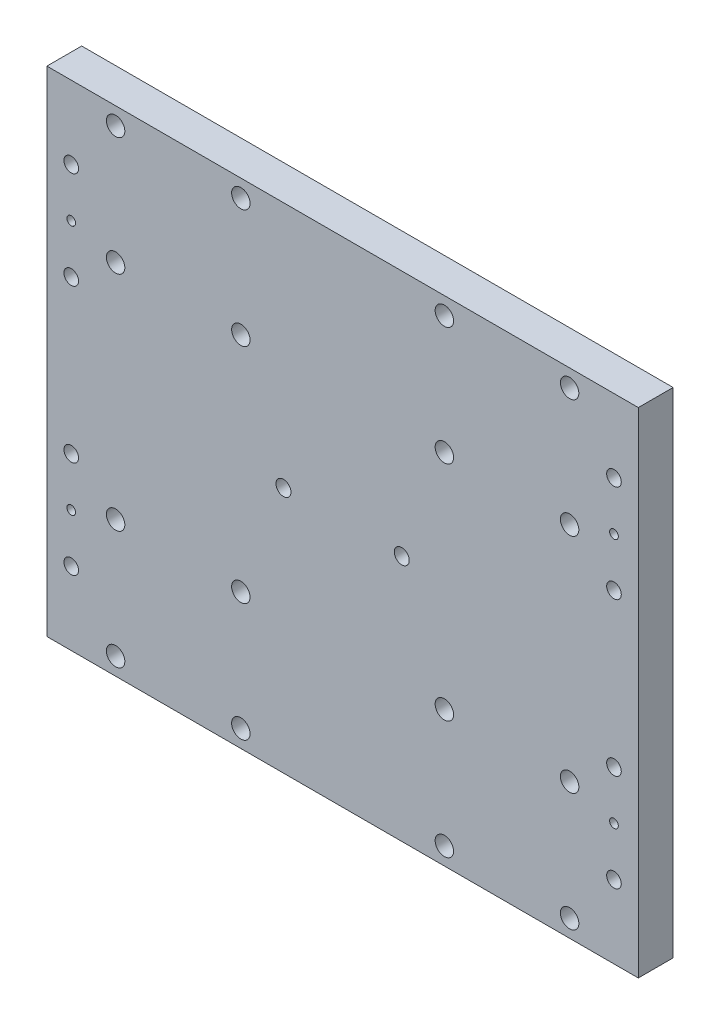
from build123d import *

# Parameters (mm, degrees)
SKETCH1_W                      = 170
SKETCH1_H                      = 142
BOSS_EXTRUDE1_DEPTH            = 5
M5_CLEARANCE_HOLE1_D           = 5.3
MIRROR3_COPY_1_D               = 5.3
M4_CLEARANCE_HOLE1_D           = 4.3
M5X0_8_TAPPED_HOLE1_AT_2_COUNT = 2
M5X0_8_TAPPED_HOLE1_AT_2_PITCH = 28
SKETCH6_R                      = 1.25
CUT_EXTRUDE5_DEPTH             = 11
MIRROR4_COPY_2_SKETCH_R        = 1.25
MIRROR4_COPY_2_DEPTH           = 11


with BuildPart() as part:
    # Sketch1 → Boss-Extrude1 (new body, symmetric)
    with BuildSketch(Plane.XY):
        Rectangle(SKETCH1_W, SKETCH1_H)
    extrude(amount=BOSS_EXTRUDE1_DEPTH, both=True)

    # M5 Clearance Hole1 (through all)
    with Locations(Plane.XY.offset(5)):
        with Locations((-65.25, 66), (-29.25, 66), (-29.25, 32), (-65.25, 32)):
            m5_clearance_hole1 = Hole(M5_CLEARANCE_HOLE1_D / 2)

    # Mirror2: M5 Clearance Hole1 across plane
    add(m5_clearance_hole1.mirror(Plane.ZX), mode=Mode.SUBTRACT)

    # Mirror3: M5 Clearance Hole1 across plane
    add(m5_clearance_hole1.mirror(Plane(origin=(0, 0, 0), x_dir=(0, 0, 1), z_dir=(1, 0, 0))), mode=Mode.SUBTRACT)

    # Mirror3 copy 1 (through all)
    with Locations(Plane(origin=(0, 0, 5), x_dir=(-1, 0, 0), z_dir=(0, 0, 1))):
        with Locations((-65.25, 66), (-29.25, 66), (-29.25, 32), (-65.25, 32)):
            Hole(MIRROR3_COPY_1_D / 2)

    # M4 Clearance Hole1 (through all)
    with Locations(Plane.XY.offset(5)):
        with Locations((-17, 0), (17, 0)):
            Hole(M4_CLEARANCE_HOLE1_D / 2)

    # Sketch11 → M5x0.8 Tapped Hole1 (revolve, cut)
    with BuildSketch(Plane(origin=(-78, 50, 5), x_dir=(0, -1, 0), z_dir=(1, 0, 0))):
        Polygon((0, 0), (0, 15.2618073), (2.1, 14), (2.1, 0), align=None)
    m5x0_8_tapped_hole1 = revolve(axis=Axis((-78, 50, 11.35), (0, 0, -1)), mode=Mode.SUBTRACT)

    # M5x0.8 Tapped Hole1 at 2: M5x0.8 Tapped Hole1 ×2
    with Locations(*[(0, -i * M5X0_8_TAPPED_HOLE1_AT_2_PITCH, 0) for i in range(1, M5X0_8_TAPPED_HOLE1_AT_2_COUNT)]):
        add(m5x0_8_tapped_hole1, mode=Mode.SUBTRACT)

    # Sketch6 → Cut-Extrude5 (cut, through all)
    with BuildSketch(Plane.XY.offset(5)):
        with Locations((-78, 36)):
            Circle(SKETCH6_R)
    cut_extrude5 = extrude(amount=-CUT_EXTRUDE5_DEPTH, mode=Mode.SUBTRACT)

    # Mirror1: M5x0.8 Tapped Hole1, Cut-Extrude5 across plane
    add(m5x0_8_tapped_hole1.mirror(Plane(origin=(0, 0, 0), x_dir=(0, 0, 1), z_dir=(1, 0, 0))), mode=Mode.SUBTRACT)
    add(cut_extrude5.mirror(Plane(origin=(0, 0, 0), x_dir=(0, 0, 1), z_dir=(1, 0, 0))), mode=Mode.SUBTRACT)

    # Mirror1 copy 1 sketch → Mirror1 copy 1 (revolve, cut)
    with BuildSketch(Plane(origin=(78, 22, 5), x_dir=(0, -1, 0), z_dir=(-1, 0, 0))):
        Polygon((0, 0), (0, -15.2618073), (2.1, -14), (2.1, 0), align=None)
    revolve(axis=Axis((78, 22, 11.35), (0, 0, 1)), mode=Mode.SUBTRACT)

    # Mirror4: M5x0.8 Tapped Hole1, Cut-Extrude5 across plane
    add(m5x0_8_tapped_hole1.mirror(Plane.ZX), mode=Mode.SUBTRACT)
    add(cut_extrude5.mirror(Plane.ZX), mode=Mode.SUBTRACT)

    # Mirror4 copy 1 sketch → Mirror4 copy 1 (revolve, cut)
    with BuildSketch(Plane(origin=(78, -50, 5), x_dir=(0, 1, 0), z_dir=(-1, 0, 0))):
        Polygon((0, 0), (0, 15.2618073), (2.1, 14), (2.1, 0), align=None)
    revolve(axis=Axis((78, -50, 11.35), (0, 0, -1)), mode=Mode.SUBTRACT)

    # Mirror4 copy 2 sketch → Mirror4 copy 2 (cut, through all)
    with BuildSketch(Plane(origin=(0, 0, 5), x_dir=(-1, 0, 0), z_dir=(0, 0, 1))):
        with Locations((-78, 36)):
            Circle(MIRROR4_COPY_2_SKETCH_R)
    extrude(amount=-MIRROR4_COPY_2_DEPTH, mode=Mode.SUBTRACT)

    # Mirror4 copy 3 sketch → Mirror4 copy 3 (revolve, cut)
    with BuildSketch(Plane(origin=(78, -22, 5), x_dir=(0, 1, 0), z_dir=(-1, 0, 0))):
        Polygon((0, 0), (0, 15.2618073), (2.1, 14), (2.1, 0), align=None)
    revolve(axis=Axis((78, -22, 11.35), (0, 0, -1)), mode=Mode.SUBTRACT)

    # Mirror4 copy 4 sketch → Mirror4 copy 4 (revolve, cut)
    with BuildSketch(Plane(origin=(-78, -22, 5), x_dir=(0, 1, 0), z_dir=(1, 0, 0))):
        Polygon((0, 0), (0, -15.2618073), (2.1, -14), (2.1, 0), align=None)
    revolve(axis=Axis((-78, -22, 11.35), (0, 0, 1)), mode=Mode.SUBTRACT)


solid = part.part
